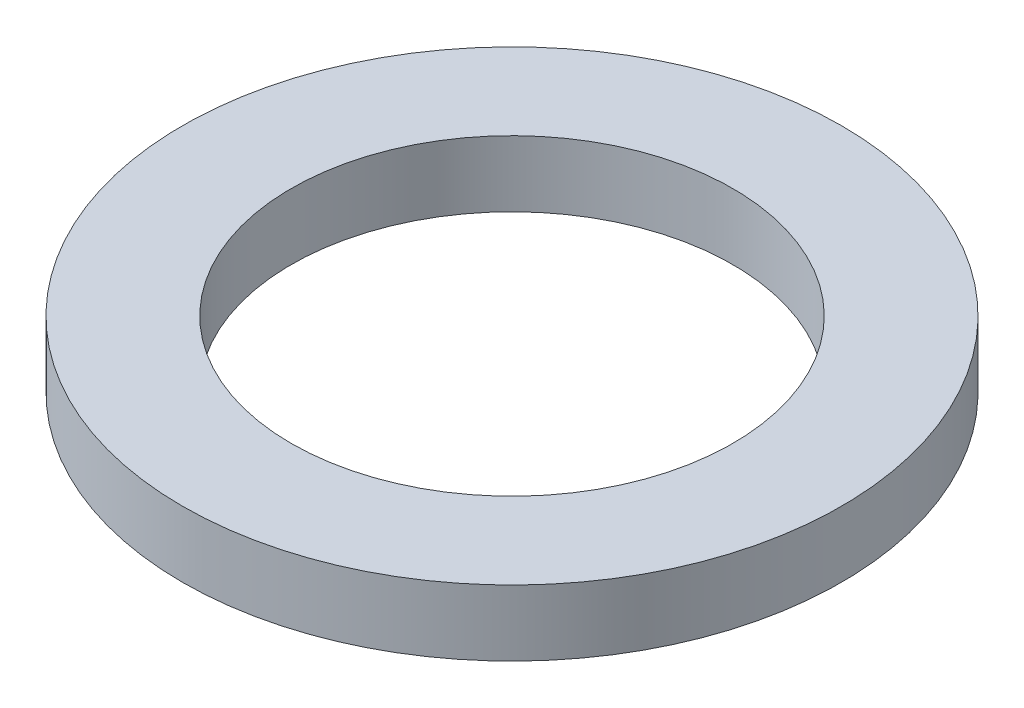
from build123d import *

# Parameters (mm, degrees)
SKETCH1_R           = 5
SKETCH1_R_2         = 3.35
BOSS_EXTRUDE1_DEPTH = 1


with BuildPart() as part:
    # Sketch1 → Boss-Extrude1 (new body)
    with BuildSketch(Plane(origin=(0, 0, 0), x_dir=(1, 0, 0), z_dir=(0, 1, 0))):
        Circle(SKETCH1_R)
        Circle(SKETCH1_R_2, mode=Mode.SUBTRACT)
    extrude(amount=BOSS_EXTRUDE1_DEPTH)


solid = part.part
